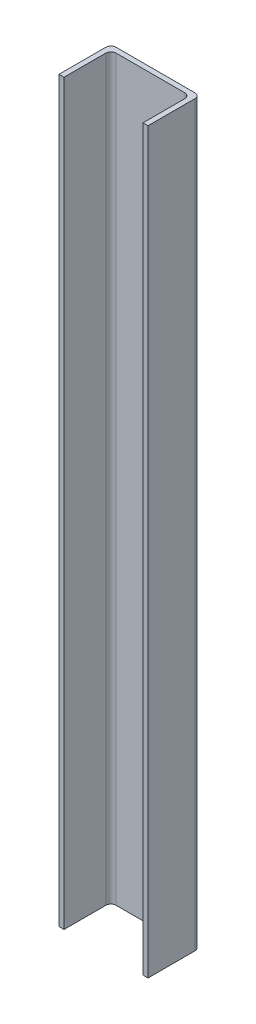
from build123d import *

# Parameters (mm, degrees)
BOSS_EXTRUDE1_DEPTH = 631.317


with BuildPart() as part:
    # Sketch1 → Boss-Extrude1 (new body)
    with BuildSketch(Plane(origin=(0, 0, 0), x_dir=(1, 0, 0), z_dir=(0, 1, 0))):
        with BuildLine():
            Line((-38.1, -22.225), (-33.782, -22.225))
            Line((-33.782, -22.225), (-33.782, 13.589))
            ThreePointArc((-33.782, 13.589), (-32.517287081, 16.642287081), (-29.464, 17.907))
            Line((-29.464, 17.907), (29.464, 17.907))
            ThreePointArc((29.464, 17.907), (32.517287081, 16.642287081), (33.782, 13.589))
            Line((33.782, 13.589), (33.782, -22.225))
            Line((33.782, -22.225), (38.1, -22.225))
            Line((38.1, -22.225), (38.1, 17.907))
            ThreePointArc((38.1, 17.907), (36.835287081, 20.960287081), (33.782, 22.225))
            Line((33.782, 22.225), (-33.782, 22.225))
            ThreePointArc((-33.782, 22.225), (-36.835287081, 20.960287081), (-38.1, 17.907))
            Line((-38.1, 17.907), (-38.1, -22.225))
        make_face()
    extrude(amount=BOSS_EXTRUDE1_DEPTH)


solid = part.part
